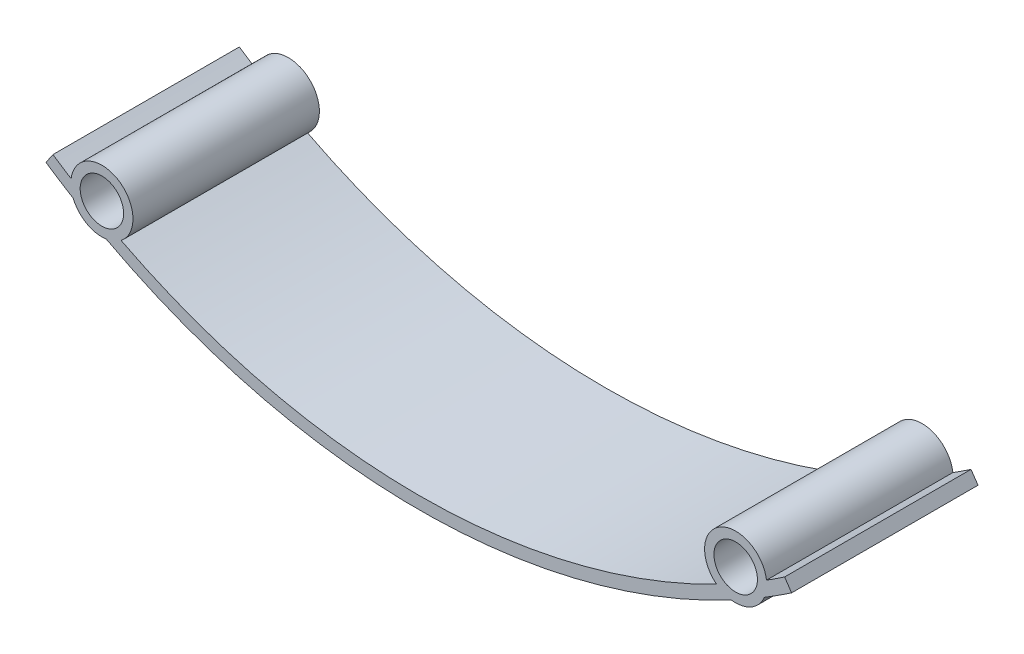
from build123d import *

# Parameters (mm, degrees)
SKETCH1_R           = 3.5
BOSS_EXTRUDE1_DEPTH = 30


with BuildPart() as part:
    # Sketch1 → Boss-Extrude1 (new body)
    with BuildSketch(Plane.XY):
        with BuildLine():
            Line((-60, 18.405417773), (-58.878504673, 20.061391272))
            ThreePointArc((-58.878504673, 20.061391272), (-57.426520301, 19.095536142), (-55.958695403, 18.153928569))
            ThreePointArc((-55.958695403, 18.153928569), (-48.524271845, 21.85662068), (-47.920935099, 13.573108907))
            ThreePointArc((-47.920935099, 13.573108907), (0, 2), (47.920935099, 13.573108907))
            ThreePointArc((47.920935099, 13.573108907), (48.524271845, 21.85662068), (55.958695403, 18.153928569))
            ThreePointArc((55.958695403, 18.153928569), (57.426520301, 19.095536142), (58.878504673, 20.061391272))
            Line((58.878504673, 20.061391272), (60, 18.405417773))
            ThreePointArc((60, 18.405417773), (57.824766419, 16.970580427), (55.615236982, 15.589139511))
            ThreePointArc((55.615236982, 15.589139511), (53.475728155, 13.16852075), (50.302662914, 12.561437412))
            ThreePointArc((50.302662914, 12.561437412), (0, 0), (-50.302662914, 12.561437412))
            ThreePointArc((-50.302662914, 12.561437412), (-53.475728155, 13.16852075), (-55.615236982, 15.589139511))
            ThreePointArc((-55.615236982, 15.589139511), (-57.824766419, 16.970580427), (-60, 18.405417773))
        make_face()
        with Locations((-51, 17.512570715)):
            Circle(SKETCH1_R, mode=Mode.SUBTRACT)
        with Locations((51, 17.512570715)):
            Circle(SKETCH1_R, mode=Mode.SUBTRACT)
    extrude(amount=BOSS_EXTRUDE1_DEPTH)


solid = part.part
